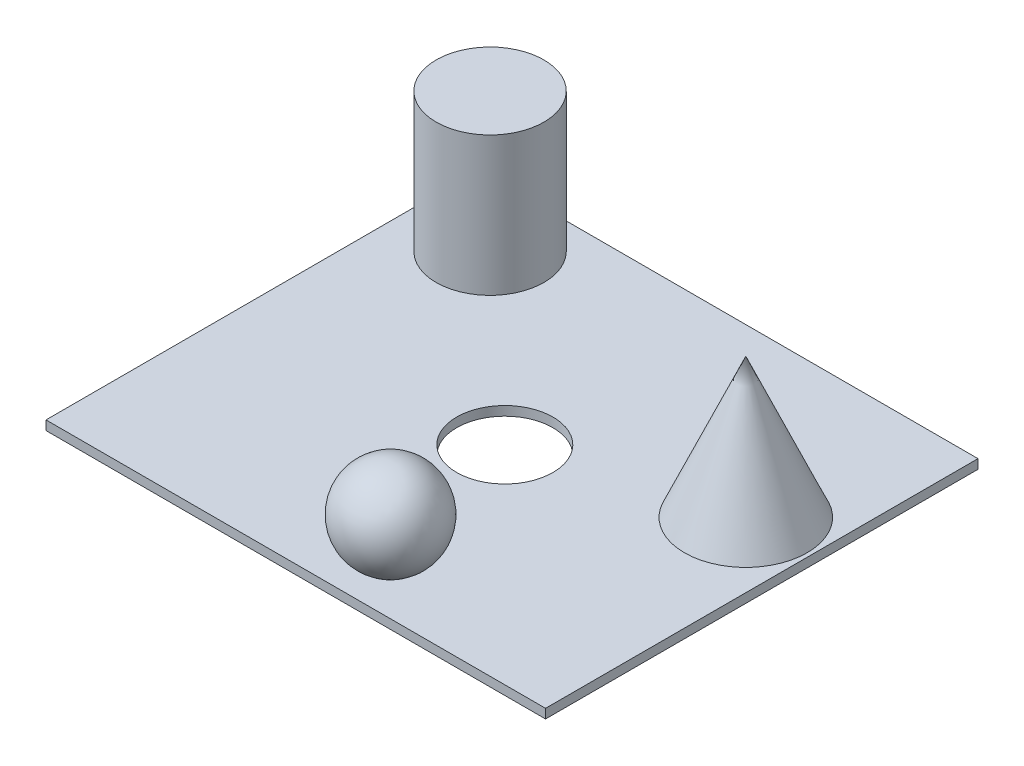
from build123d import *

# Parameters (mm, degrees)
SKETCH_1_W          = 107.889647592
SKETCH_1_H          = 93.399614016
EXTRUDE_1_DEPTH     = 2
SKETCH_2_R          = 11.639752959
EXTRUDE_2_DEPTH     = 30
SKETCH_3_R          = 10.388227947
CUT_EXTRUDE_1_DEPTH = 30


with BuildPart() as part:
    # 草图1 → 凸台-拉伸1 (new body)
    with BuildSketch(Plane(origin=(0, 0, 0), x_dir=(1, 0, 0), z_dir=(0, 1, 0))):
        with Locations((-9.950986914, -10.649301785)):
            Rectangle(SKETCH_1_W, SKETCH_1_H)
    extrude(amount=EXTRUDE_1_DEPTH)

    # 草图2 → 凸台-拉伸2 (add)
    with BuildSketch(Plane(origin=(0, 2, 0), x_dir=(1, 0, 0), z_dir=(0, 1, 0))):
        with Locations((-47.461132716, 22.11962872)):
            Circle(SKETCH_2_R)
    extrude(amount=EXTRUDE_2_DEPTH)

    # 草图3 → 切除-拉伸1 (cut)
    with BuildSketch(Plane(origin=(0, 2, 0), x_dir=(1, 0, 0), z_dir=(0, 1, 0))):
        with Locations((-9.699240969, -12.453481057)):
            Circle(SKETCH_3_R)
    extrude(amount=-CUT_EXTRUDE_1_DEPTH, mode=Mode.SUBTRACT)

    # 草图6 → 旋转4 (revolve)
    with BuildSketch(Plane(origin=(0, 0, 0), x_dir=(0, 0, -1), z_dir=(1, 0, 0))):
        with BuildLine():
            Line((-46.832059877, 2), (-42.473160934, 2))
            ThreePointArc((-42.473160934, 2), (-37.085265533, 13.236067977), (-46.832059877, 21))
            Line((-46.832059877, 21), (-46.832059877, 2))
        make_face()
    revolve(axis=Axis((0, 24.008191083, 46.832059877), (0, -1, 0)))

    # 草图7 → 旋转5 (revolve)
    with BuildSketch(Plane.XY):
        Polygon((16.639758733, 2), (29.897679802, 32.14170616), (29.897679802, 2), align=None)
    revolve(axis=Axis((29.897679802, 32.14170616, 0), (0, -1, 0)))


solid = part.part
